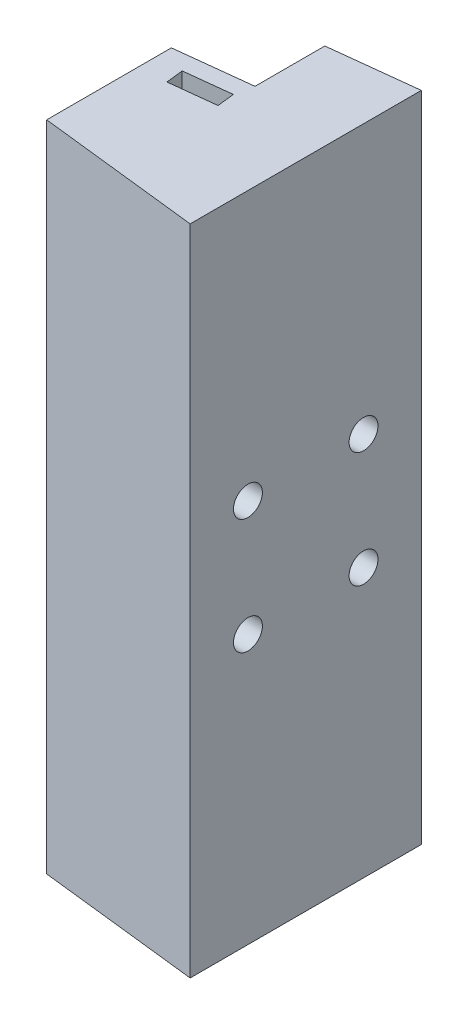
from build123d import *

# Parameters (mm, degrees)
BOSS_EXTRUDE1_DEPTH = 56.5
SKETCH2_R           = 2.5
CUT_EXTRUDE1_DEPTH  = 20
SKETCH5_R           = 5
CUT_EXTRUDE4_DEPTH  = 22
CUT_EXTRUDE5_DEPTH  = 126
SKETCH7_R           = 2
CUT_EXTRUDE6_DEPTH  = 6
CUT_EXTRUDE7_DEPTH  = 3
SKETCH10_R          = 2
CUT_EXTRUDE8_DEPTH  = 2


with BuildPart() as part:
    # Sketch1 → Boss-Extrude1 (new body, symmetric)
    with BuildSketch(Plane(origin=(0, 0, 0), x_dir=(1, 0, 0), z_dir=(0, 1, 0))):
        Polygon((0, 0), (-28, -3.175346835), (-28, -36.824653165), (0, -40), align=None)
    extrude(amount=BOSS_EXTRUDE1_DEPTH, both=True)

    # Sketch2 → Cut-Extrude1 (cut)
    with BuildSketch(Plane(origin=(0, 0, 0), x_dir=(0, 0, -1), z_dir=(1, 0, 0))):
        with Locations((-10, 10)):
            Circle(SKETCH2_R)
        with Locations((-10, -10)):
            Circle(SKETCH2_R)
        with Locations((-30, 10)):
            Circle(SKETCH2_R)
        with Locations((-30, -10)):
            Circle(SKETCH2_R)
    extrude(amount=-CUT_EXTRUDE1_DEPTH, mode=Mode.SUBTRACT)

    # Sketch5 → Cut-Extrude4 (cut)
    with BuildSketch(Plane.ZY.offset(28)):
        with Locations((30, 10)):
            Circle(SKETCH5_R)
        with Locations((30, -10)):
            Circle(SKETCH5_R)
        with Locations((10, -10)):
            Circle(SKETCH5_R)
        with Locations((10, 10)):
            Circle(SKETCH5_R)
    extrude(amount=-CUT_EXTRUDE4_DEPTH, mode=Mode.SUBTRACT)

    # Sketch6 → Cut-Extrude5 (cut)
    with BuildSketch(Plane.XZ.offset(56.5)):
        Polygon((-15, 1.701078662), (-15, 13.777996642), (-28, 15.252264816), (-28, 3.175346835), align=None)
    extrude(amount=-CUT_EXTRUDE5_DEPTH, mode=Mode.SUBTRACT)

    # Sketch7 → Cut-Extrude6 (cut)
    with BuildSketch(Plane(origin=(1.352195583, 0, 11.92357191), x_dir=(-0.993630993, 0, 0.112682965), z_dir=(-0.112682965, 0, -0.993630993))):
        with Locations((21.457010405, -51.5)):
            Circle(SKETCH7_R)
        with Locations((21.457010405, 51.5)):
            Circle(SKETCH7_R)
    extrude(amount=-CUT_EXTRUDE6_DEPTH, mode=Mode.SUBTRACT)

    # Sketch9 → Cut-Extrude7 (cut)
    with BuildSketch(Plane(origin=(2.028293375, 0, 17.885357866), x_dir=(-0.993630993, 0, 0.112682965), z_dir=(-0.112682965, 0, -0.993630993))):
        with BuildLine():
            Line((17.457010405, -51.5), (17.457010405, -56.5))
            Line((17.457010405, -56.5), (25.457010405, -56.5))
            Line((25.457010405, -56.5), (25.457010405, -51.5))
            ThreePointArc((25.457010405, -51.5), (21.457010405, -47.5), (17.457010405, -51.5))
        make_face()
        with BuildLine():
            Line((17.457010405, 56.5), (17.457010405, 51.5))
            ThreePointArc((17.457010405, 51.5), (21.457010405, 47.5), (25.457010405, 51.5))
            Line((25.457010405, 51.5), (25.457010405, 56.5))
            Line((25.457010405, 56.5), (17.457010405, 56.5))
        make_face()
    extrude(amount=CUT_EXTRUDE7_DEPTH, mode=Mode.SUBTRACT)

    # Sketch10 → Cut-Extrude8 (cut)
    with BuildSketch(Plane(origin=(2.028293375, 0, 17.885357866), x_dir=(-0.993630993, 0, 0.112682965), z_dir=(-0.112682965, 0, -0.993630993))):
        with Locations((21.457010405, 51.5)):
            Circle(SKETCH10_R)
        with Locations((21.457010405, -51.5)):
            Circle(SKETCH10_R)
    extrude(amount=-CUT_EXTRUDE8_DEPTH, mode=Mode.SUBTRACT)


solid = part.part
